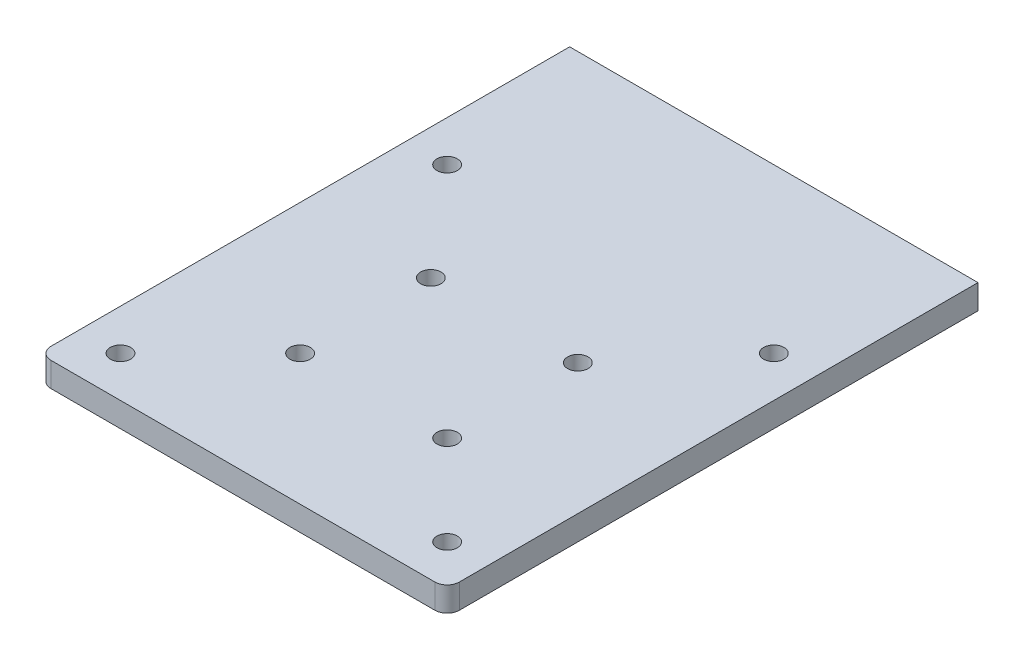
from build123d import *

# Parameters (mm, degrees)
SKETCH1_W           = 100
SKETCH1_H           = 130
SKETCH1_R           = 2.5
BOSS_EXTRUDE1_DEPTH = 6
FILLET1_R           = 3


with BuildPart() as part:
    # Sketch1 → Boss-Extrude1 (new body)
    with BuildSketch(Plane(origin=(0, 0, 0), x_dir=(1, 0, 0), z_dir=(0, 1, 0))):
        with Locations((40, 55)):
            Rectangle(SKETCH1_W, SKETCH1_H)
        Circle(SKETCH1_R, mode=Mode.SUBTRACT)
        with Locations((80, 0)):
            Circle(SKETCH1_R, mode=Mode.SUBTRACT)
        with Locations((0, 80)):
            Circle(SKETCH1_R, mode=Mode.SUBTRACT)
        with Locations((80, 80)):
            Circle(SKETCH1_R, mode=Mode.SUBTRACT)
        with Locations((22, 22)):
            Circle(SKETCH1_R, mode=Mode.SUBTRACT)
        with Locations((58, 22)):
            Circle(SKETCH1_R, mode=Mode.SUBTRACT)
        with Locations((22, 54)):
            Circle(SKETCH1_R, mode=Mode.SUBTRACT)
        with Locations((58, 54)):
            Circle(SKETCH1_R, mode=Mode.SUBTRACT)
    extrude(amount=BOSS_EXTRUDE1_DEPTH)

    # Fillet1
    fillet1_edges = [part.edges().sort_by_distance(p)[0] for p in [
        (90, 3, 10),
        (-10, 3, 10),
    ]]
    fillet(fillet1_edges, radius=FILLET1_R)


solid = part.part
